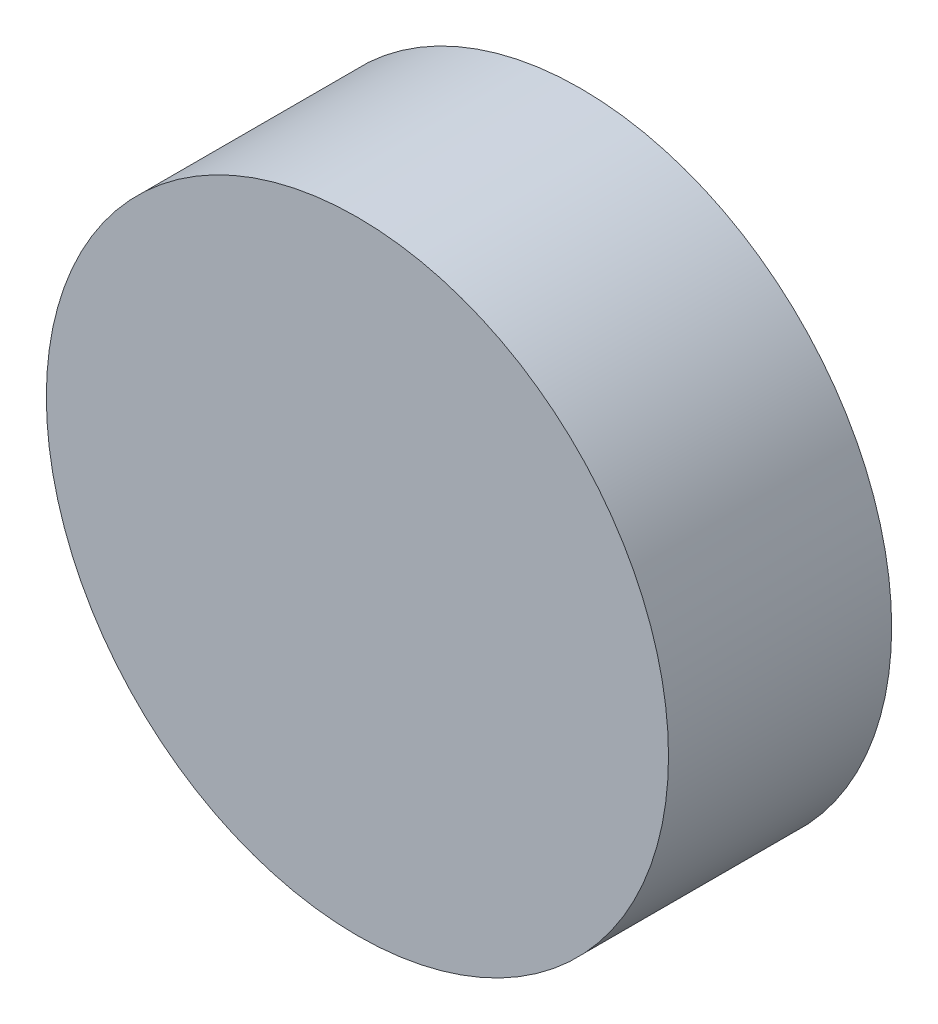
from build123d import *

# Parameters (mm, degrees)
SKETCH1_R           = 75
BOSS_EXTRUDE1_DEPTH = 53.8


with BuildPart() as part:
    # Sketch1 → Boss-Extrude1 (new body)
    with BuildSketch(Plane.XY):
        Circle(SKETCH1_R)
    extrude(amount=BOSS_EXTRUDE1_DEPTH)


solid = part.part
